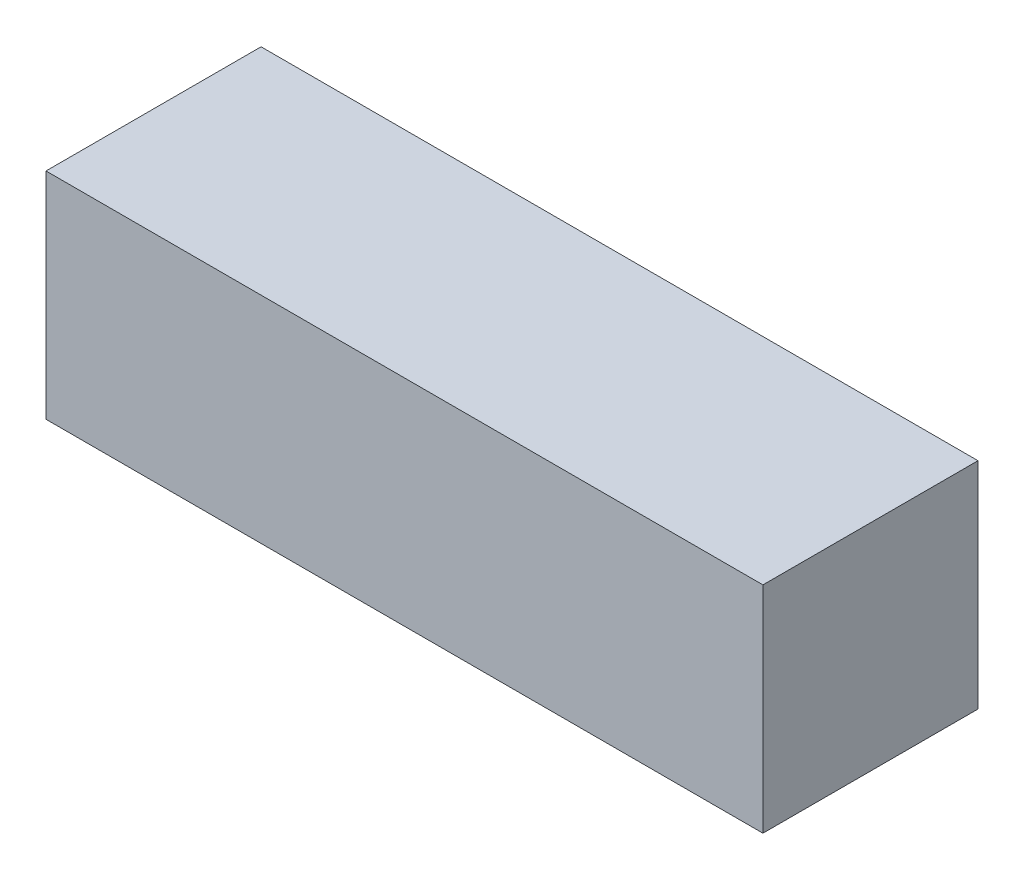
from build123d import *

# Parameters (mm, degrees)
SKETCH1_W           = 200
SKETCH1_H           = 60
BOSS_EXTRUDE1_DEPTH = 60


with BuildPart() as part:
    # Sketch1 → Boss-Extrude1 (new body)
    with BuildSketch(Plane(origin=(0, 0, 0), x_dir=(1, 0, 0), z_dir=(0, 1, 0))):
        Rectangle(SKETCH1_W, SKETCH1_H)
    extrude(amount=BOSS_EXTRUDE1_DEPTH)


solid = part.part
